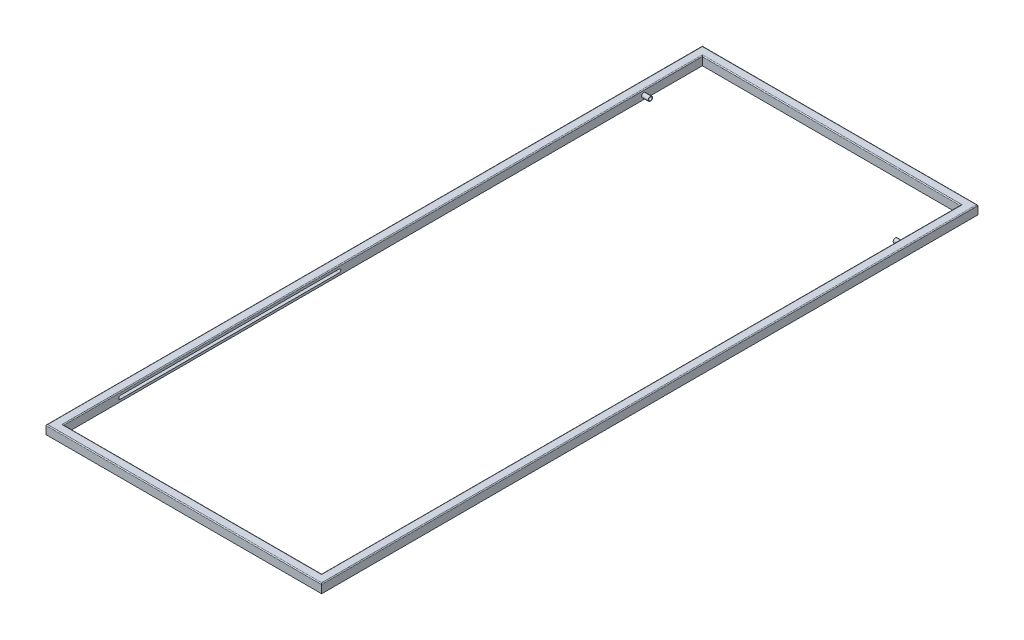
from build123d import *

# Parameters (mm, degrees)
CROQUIS1_W                 = 630
CROQUIS1_H                 = 1500
CROQUIS1_W_2               = 590
CROQUIS1_H_2               = 1460
SALIENTE_EXTRUIR1_DEPTH    = 20
CROQUIS2_R                 = 5
CORTAR_EXTRUIR1_DEPTH      = 15
REDONDEO1_R                = 2
CORTAR_EXTRUIR2_DEPTH      = 605
CORTAR_EXTRUIR2_DEPTH_BACK = 15
CROQUIS5_R                 = 5
CROQUIS5_R_2               = 3.75
SALIENTE_EXTRUIR2_DEPTH    = 15
ESCALA1_SCALE              = 1.3


with BuildPart() as part:
    # Croquis1 → Saliente-Extruir1 (new body)
    with BuildSketch(Plane(origin=(0, 0, 0), x_dir=(1, 0, 0), z_dir=(0, 1, 0))):
        Rectangle(CROQUIS1_W, CROQUIS1_H)
        Rectangle(CROQUIS1_W_2, CROQUIS1_H_2, mode=Mode.SUBTRACT)
    extrude(amount=SALIENTE_EXTRUIR1_DEPTH)

    # Croquis2 → Cortar-Extruir1 (cut)
    with BuildSketch(Plane.XZ):
        with Locations((-305, 740)):
            Circle(CROQUIS2_R)
        with Locations((305, 740)):
            Circle(CROQUIS2_R)
        with Locations((305, -740)):
            Circle(CROQUIS2_R)
        with Locations((-305, -740)):
            Circle(CROQUIS2_R)
    extrude(amount=-CORTAR_EXTRUIR1_DEPTH, mode=Mode.SUBTRACT)

    # Redondeo1
    redondeo1_edges = [part.edges().sort_by_distance(p)[0] for p in [
        (-315, 20, 0),
        (295, 20, 0),
        (0, 20, 750),
        (0, 20, -730),
        (-295, 20, 0),
        (0, 20, 730),
        (315, 20, 0),
        (0, 20, -750),
    ]]
    fillet(redondeo1_edges, radius=REDONDEO1_R)

    # Croquis4 → Cortar-Extruir2 (cut, two sides)
    with BuildSketch(Plane.ZY.offset(-295)) as cortar_extruir2_sk:
        with BuildLine():
            Line((600, 12.75), (100, 12.75))
            Line((100, 12.75), (100, 5.25))
            Line((100, 5.25), (600, 5.25))
            ThreePointArc((600, 5.25), (603.75, 9), (600, 12.75))
        make_face()
        with BuildLine():
            Line((100, 5.25), (100, 12.75))
            ThreePointArc((100, 12.75), (96.25, 9), (100, 5.25))
        make_face()
    extrude(amount=CORTAR_EXTRUIR2_DEPTH, mode=Mode.SUBTRACT)
    extrude(cortar_extruir2_sk.sketch, amount=-CORTAR_EXTRUIR2_DEPTH_BACK, mode=Mode.SUBTRACT)

    # Croquis5 → Saliente-Extruir2 (add)
    with BuildSketch(Plane.ZY.offset(-295)):
        with Locations((-596.25, 9)):
            Circle(CROQUIS5_R)
        with Locations((-596.25, 9)):
            Circle(CROQUIS5_R_2, mode=Mode.SUBTRACT)
    saliente_extruir2 = extrude(amount=SALIENTE_EXTRUIR2_DEPTH)

    # Simetría1: Saliente-Extruir2 across plane
    add(saliente_extruir2.mirror(Plane(origin=(0, 0, 0), x_dir=(0, 0, 1), z_dir=(1, 0, 0))))


with BuildPart() as part_1:
    # Escala1: scaled about (0, 0, 0)
    add(part.part.scale(ESCALA1_SCALE))


solid = part_1.part
